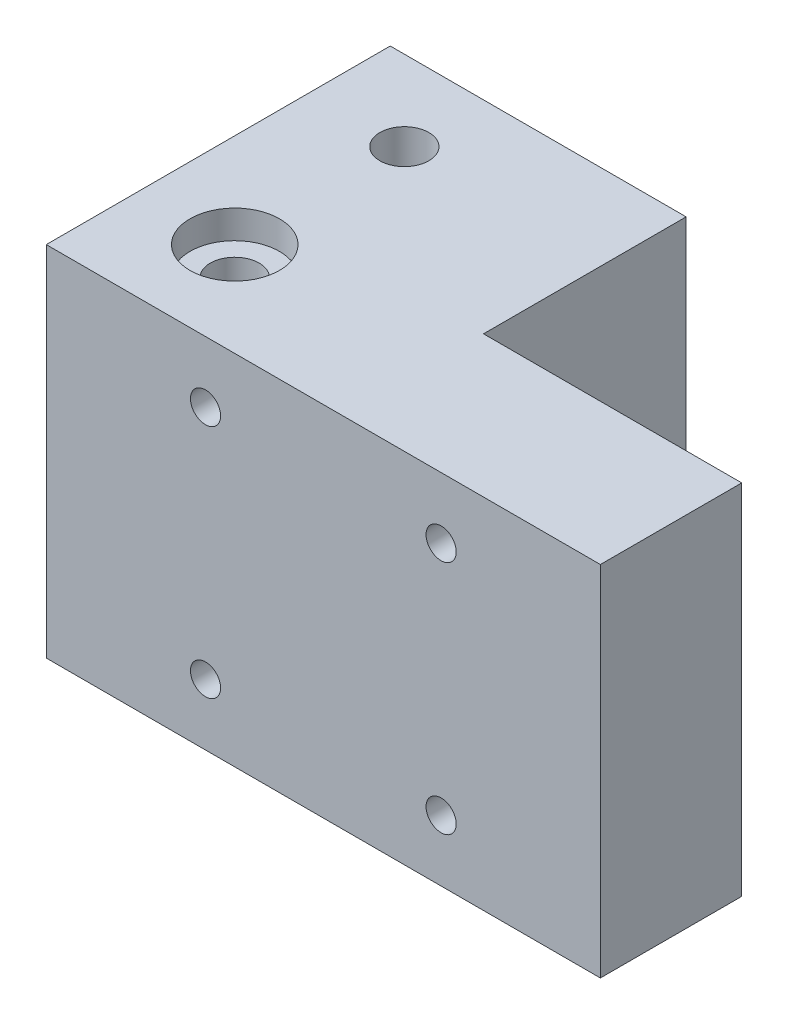
from build123d import *

# Parameters (mm, degrees)
SKETCH_1_W                = 58.8
SKETCH_1_H                = 32
EXTRUDE_1_DEPTH           = 41.5
HOLE_WIZARD_1_D           = 3.2
HOLE_WIZARD_1_CBORE_D     = 6
HOLE_WIZARD_1_CBORE_DEPTH = 32.5
SKETCH_8_R                = 2.6
CUT_EXTRUDE_6_DEPTH       = 33.5
SKETCH_10_W               = 58.8
SKETCH_10_H               = 41.5
EXTRUDE_2_DEPTH           = 3
SKETCH_18_R               = 2.6
CUT_EXTRUDE_14_DEPTH      = 4
SKETCH_19_W               = 20
SKETCH_19_H               = 20
SKETCH_19_R               = 3
CUT_EXTRUDE_15_DEPTH      = 22
SKETCH_20_R               = 3
CUT_EXTRUDE_16_DEPTH      = 5
CUT_EXTRUDE_17_DEPTH      = 6
SKETCH_22_W               = 27.4
SKETCH_22_H               = 21.5
CUT_EXTRUDE_18_DEPTH      = 36
SKETCH_23_R               = 2.6
CUT_EXTRUDE_19_DEPTH      = 16
CUT_EXTRUDE_20_DEPTH      = 6
SKETCH_25_W               = 20
SKETCH_25_H               = 17
SKETCH_25_R               = 2.6
CUT_EXTRUDE_21_DEPTH      = 0.1
SKETCH_27_W               = 17
SKETCH_27_H               = 20.1
CUT_EXTRUDE_22_DEPTH      = 0.1
SKETCH_28_R               = 2.6
CUT_EXTRUDE_23_DEPTH      = 39.7
SKETCH_29_R               = 4.5
SKETCH_29_R_2             = 2.6
CUT_EXTRUDE_24_DEPTH      = 5
SKETCH_30_R               = 2.6
CUT_EXTRUDE_25_DEPTH      = 36.0000001
SKETCH_31_R               = 2.6
EXTRUDE_3_DEPTH           = 35
SKETCH_32_W               = 20.1
SKETCH_32_H               = 17
SKETCH_32_R               = 2.6
CUT_EXTRUDE_26_DEPTH      = 7
SKETCH_33_W               = 20.1
SKETCH_33_H               = 7
SKETCH_33_R               = 3
EXTRUDE_4_DEPTH           = 17
SKETCH_34_R               = 4.5
EXTRUDE_5_DEPTH           = 5
SKETCH_35_R               = 2.6
EXTRUDE_6_DEPTH           = 6.3
SKETCH_39_R               = 2.6
CUT_EXTRUDE_29_DEPTH      = 8
SKETCH_40_W               = 20.1
SKETCH_40_H               = 17
SKETCH_40_R               = 2.6
EXTRUDE_7_DEPTH           = 7.9
SKETCH_41_W               = 20.1
SKETCH_41_H               = 17
CUT_EXTRUDE_30_DEPTH      = 7.9
SKETCH_42_R               = 2.6
CUT_EXTRUDE_31_DEPTH      = 39.7
SKETCH_43_R               = 4.5
SKETCH_43_R_2             = 2.6
CUT_EXTRUDE_32_DEPTH      = 5.2
SKETCH_44_R               = 2.6
EXTRUDE_8_DEPTH           = 3
SKETCH_46_R               = 4.75
SKETCH_46_R_2             = 2.6
CUT_EXTRUDE_33_DEPTH      = 3


with BuildPart() as part:
    # 草图1 → 凸台-拉伸1 (new body)
    with BuildSketch(Plane.XY):
        with Locations((-0.739622642, 3.045283019)):
            Rectangle(SKETCH_1_W, SKETCH_1_H)
    extrude(amount=EXTRUDE_1_DEPTH)

    # 孔1 (through all)
    with Locations(Plane(origin=(11.760377358, 15.545283019, 0), x_dir=(-1, 0, 0), z_dir=(0, 0, -1))):
        with Locations((0, 0), (25, 0), (25, -25), (0, -25)):
            CounterBoreHole(HOLE_WIZARD_1_D / 2, HOLE_WIZARD_1_CBORE_D / 2, HOLE_WIZARD_1_CBORE_DEPTH)

    # 草图8 → 切除-拉伸6 (cut)
    with BuildSketch(Plane(origin=(0, 19.045283019, 0), x_dir=(1, 0, 0), z_dir=(0, 1, 0))):
        with Locations((-0.739622642, -31.5)):
            Circle(SKETCH_8_R)
    extrude(amount=-CUT_EXTRUDE_6_DEPTH, mode=Mode.SUBTRACT)

    # 草图10 → 凸台-拉伸2 (add)
    with BuildSketch(Plane.XZ.offset(12.954716981)):
        with Locations((-0.739622642, 20.75)):
            Rectangle(SKETCH_10_W, SKETCH_10_H)
    extrude(amount=EXTRUDE_2_DEPTH)

    # 草图18 → 切除-拉伸14 (cut, through all)
    with BuildSketch(Plane(origin=(0, -12.954716981, 0), x_dir=(1, 0, 0), z_dir=(0, 1, 0))):
        with Locations((-0.739622642, -31.5)):
            Circle(SKETCH_18_R)
    extrude(amount=-CUT_EXTRUDE_14_DEPTH, mode=Mode.SUBTRACT)

    # 草图19 → 切除-拉伸15 (cut)
    with BuildSketch(Plane(origin=(0, 0, 0), x_dir=(-1, 0, 0), z_dir=(0, 0, -1))):
        with Locations((20.139622642, 9.045283019)):
            Rectangle(SKETCH_19_W, SKETCH_19_H)
        with Locations((13.239622642, 15.545283019)):
            Circle(SKETCH_19_R, mode=Mode.SUBTRACT)
    extrude(amount=-CUT_EXTRUDE_15_DEPTH, mode=Mode.SUBTRACT)

    # 草图20 → 切除-拉伸16 (cut)
    with BuildSketch(Plane(origin=(0, 0, 0), x_dir=(-1, 0, 0), z_dir=(0, 0, -1))):
        Polygon((30.139622642, -15.954716981), (30.139622642, -0.954716981), (10.139622642, -0.954716981), (10.139622642, 19.045283019), (-28.660377358, 19.045283019), (-28.660377358, -15.954716981), align=None)
        with Locations((13.239622642, -9.454716981)):
            Circle(SKETCH_20_R, mode=Mode.SUBTRACT)
        with Locations((-11.760377358, -9.454716981)):
            Circle(SKETCH_20_R, mode=Mode.SUBTRACT)
        with Locations((-11.760377358, 15.545283019)):
            Circle(SKETCH_20_R, mode=Mode.SUBTRACT)
    extrude(amount=-CUT_EXTRUDE_16_DEPTH, mode=Mode.SUBTRACT)

    # 草图21 → 切除-拉伸17 (cut)
    with BuildSketch(Plane.XZ.offset(15.954716981)):
        Polygon((-30.139622642, 19.214629022), (-17.064744213, 5), (-30.139622642, 5), align=None)
    extrude(amount=-CUT_EXTRUDE_17_DEPTH, mode=Mode.SUBTRACT)

    # 草图22 → 切除-拉伸18 (cut, through all)
    with BuildSketch(Plane(origin=(0, 19.045283019, 0), x_dir=(1, 0, 0), z_dir=(0, 1, 0))):
        with Locations((14.960377358, -15.75)):
            Rectangle(SKETCH_22_W, SKETCH_22_H)
    extrude(amount=-CUT_EXTRUDE_18_DEPTH, mode=Mode.SUBTRACT)

    # 草图23 → 切除-拉伸19 (cut, through all)
    with BuildSketch(Plane(origin=(0, -0.954716981, 0), x_dir=(1, 0, 0), z_dir=(0, 1, 0))):
        with Locations((-20.139622642, -13.5)):
            Circle(SKETCH_23_R)
    extrude(amount=-CUT_EXTRUDE_19_DEPTH, mode=Mode.SUBTRACT)

    # 草图24 → 切除-拉伸20 (cut)
    with BuildSketch(Plane(origin=(0, -15.954716981, 0), x_dir=(-1, 0, 0), z_dir=(0, -1, 0))):
        with BuildLine():
            ThreePointArc((20.787086214, -9.046822379), (16.827633547, -16.546428767), (24.631280369, -13.22611889))
            Line((24.631280369, -13.22611889), (20.787086214, -9.046822379))
        make_face()
        with BuildLine():
            ThreePointArc((20.139622642, -16.1), (18.30114501, -11.661522369), (22.739622642, -13.5))
            ThreePointArc((22.739622642, -13.5), (21.978100273, -15.338477631), (20.139622642, -16.1))
        make_face(mode=Mode.SUBTRACT)
    extrude(amount=-CUT_EXTRUDE_20_DEPTH, mode=Mode.SUBTRACT)

    # 草图25 → 切除-拉伸21 (cut)
    with BuildSketch(Plane(origin=(0, -0.954716981, 0), x_dir=(1, 0, 0), z_dir=(0, 1, 0))):
        with Locations((-20.139622642, -13.5)):
            Rectangle(SKETCH_25_W, SKETCH_25_H)
        with Locations((-20.139622642, -13.5)):
            Circle(SKETCH_25_R, mode=Mode.SUBTRACT)
    extrude(amount=-CUT_EXTRUDE_21_DEPTH, mode=Mode.SUBTRACT)

    # 草图27 → 切除-拉伸22 (cut)
    with BuildSketch(Plane.ZY.offset(10.139622642)):
        with Locations((13.5, 8.995283019)):
            Rectangle(SKETCH_27_W, SKETCH_27_H)
    extrude(amount=-CUT_EXTRUDE_22_DEPTH, mode=Mode.SUBTRACT)

    # 草图28 → 切除-拉伸23 (cut, through all)
    with BuildSketch(Plane.ZY.offset(10.039622642)):
        with Locations((13.5, 8.995283019)):
            Circle(SKETCH_28_R)
    extrude(amount=-CUT_EXTRUDE_23_DEPTH, mode=Mode.SUBTRACT)

    # 草图29 → 切除-拉伸24 (cut)
    with BuildSketch(Plane(origin=(1.260377358, 0, 0), x_dir=(0, 0, -1), z_dir=(1, 0, 0))):
        with Locations((-13.5, 8.995283019)):
            Circle(SKETCH_29_R)
        with Locations((-13.5, 8.995283019)):
            Circle(SKETCH_29_R_2, mode=Mode.SUBTRACT)
    extrude(amount=-CUT_EXTRUDE_24_DEPTH, mode=Mode.SUBTRACT)

    # 草图30 → 切除-拉伸25 (cut, through all)
    with BuildSketch(Plane(origin=(0, 19.045283019, 0), x_dir=(1, 0, 0), z_dir=(0, 1, 0))):
        with Locations((-20.139622642, -31.5)):
            Circle(SKETCH_30_R)
    extrude(amount=-CUT_EXTRUDE_25_DEPTH, mode=Mode.SUBTRACT)

    # 草图31 → 凸台-拉伸3 (add, through all)
    with BuildSketch(Plane(origin=(0, 19.045283019, 0), x_dir=(1, 0, 0), z_dir=(0, 1, 0))):
        with Locations((-0.739622642, -31.5)):
            Circle(SKETCH_31_R)
    extrude(amount=-EXTRUDE_3_DEPTH)

    # 草图32 → 切除-拉伸26 (cut)
    with BuildSketch(Plane(origin=(0, -1.054716981, 0), x_dir=(1, 0, 0), z_dir=(0, 1, 0))):
        with Locations((-20.089622642, -13.5)):
            Rectangle(SKETCH_32_W, SKETCH_32_H)
        with Locations((-20.139622642, -13.5)):
            Circle(SKETCH_32_R, mode=Mode.SUBTRACT)
    extrude(amount=-CUT_EXTRUDE_26_DEPTH, mode=Mode.SUBTRACT)

    # 草图33 → 凸台-拉伸4 (add)
    with BuildSketch(Plane(origin=(0, 0, 22), x_dir=(-1, 0, 0), z_dir=(0, 0, -1))):
        with Locations((20.089622642, 15.545283019)):
            Rectangle(SKETCH_33_W, SKETCH_33_H)
        with Locations((13.239622642, 15.545283019)):
            Circle(SKETCH_33_R, mode=Mode.SUBTRACT)
    extrude(amount=EXTRUDE_4_DEPTH)

    # 草图34 → 凸台-拉伸5 (add)
    with BuildSketch(Plane(origin=(-3.739622642, 0, 0), x_dir=(0, 0, -1), z_dir=(1, 0, 0))):
        with Locations((-13.5, 8.995283019)):
            Circle(SKETCH_34_R)
    extrude(amount=EXTRUDE_5_DEPTH)

    # 草图35 → 凸台-拉伸6 (add)
    with BuildSketch(Plane.ZY.offset(3.739622642)):
        with Locations((13.5, 8.995283019)):
            Circle(SKETCH_35_R)
    extrude(amount=EXTRUDE_6_DEPTH)

    # 草图39 → 切除-拉伸29 (cut, through all)
    with BuildSketch(Plane.XZ.offset(-12.045283019)):
        with Locations((-20.139622642, 13.5)):
            Circle(SKETCH_39_R)
    extrude(amount=-CUT_EXTRUDE_29_DEPTH, mode=Mode.SUBTRACT)

    # 草图40 → 凸台-拉伸7 (add)
    with BuildSketch(Plane.XZ.offset(-12.045283019)):
        with Locations((-20.089622642, 13.5)):
            Rectangle(SKETCH_40_W, SKETCH_40_H)
        with Locations((-20.139622642, 13.5)):
            Circle(SKETCH_40_R, mode=Mode.SUBTRACT)
    extrude(amount=EXTRUDE_7_DEPTH)

    # 草图41 → 切除-拉伸30 (cut)
    with BuildSketch(Plane(origin=(0, -8.054716981, 0), x_dir=(1, 0, 0), z_dir=(0, 1, 0))):
        with Locations((-20.089622642, -13.5)):
            Rectangle(SKETCH_41_W, SKETCH_41_H)
    extrude(amount=-CUT_EXTRUDE_30_DEPTH, mode=Mode.SUBTRACT)

    # 草图42 → 切除-拉伸31 (cut, through all)
    with BuildSketch(Plane.ZY.offset(10.039622642)):
        with Locations((13.5, -5.854716981)):
            Circle(SKETCH_42_R)
    extrude(amount=-CUT_EXTRUDE_31_DEPTH, mode=Mode.SUBTRACT)

    # 草图43 → 切除-拉伸32 (cut)
    with BuildSketch(Plane(origin=(1.260377358, 0, 0), x_dir=(0, 0, -1), z_dir=(1, 0, 0))):
        with Locations((-13.5, -5.854716981)):
            Circle(SKETCH_43_R)
        with Locations((-13.5, -5.854716981)):
            Circle(SKETCH_43_R_2, mode=Mode.SUBTRACT)
    extrude(amount=-CUT_EXTRUDE_32_DEPTH, mode=Mode.SUBTRACT)

    # 草图44 → 凸台-拉伸8 (add)
    with BuildSketch(Plane(origin=(0, 19.045283019, 0), x_dir=(1, 0, 0), z_dir=(0, 1, 0))):
        Polygon((1.260377358, -5), (-30.139622642, -5), (-30.139622642, -41.5), (28.660377358, -41.5), (28.660377358, -26.5), (1.260377358, -26.5), align=None)
        with Locations((-20.139622642, -13.5)):
            Circle(SKETCH_44_R, mode=Mode.SUBTRACT)
        with Locations((-20.139622642, -31.5)):
            Circle(SKETCH_44_R, mode=Mode.SUBTRACT)
    extrude(amount=EXTRUDE_8_DEPTH)

    # 草图46 → 切除-拉伸33 (cut)
    with BuildSketch(Plane(origin=(0, 22.045283019, 0), x_dir=(1, 0, 0), z_dir=(0, 1, 0))):
        with Locations((-20.139622642, -31.5)):
            Circle(SKETCH_46_R)
        with Locations((-20.139622642, -31.5)):
            Circle(SKETCH_46_R_2, mode=Mode.SUBTRACT)
    extrude(amount=-CUT_EXTRUDE_33_DEPTH, mode=Mode.SUBTRACT)


solid = part.part
